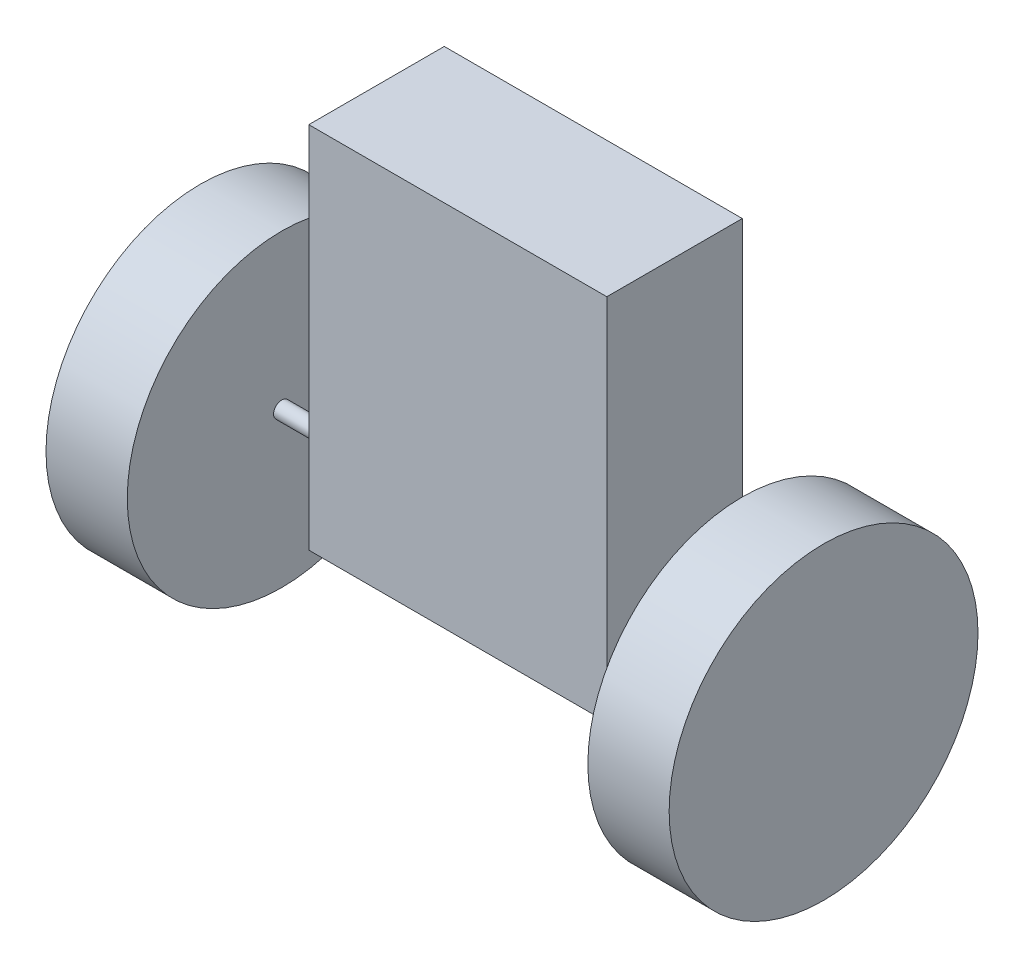
from build123d import *

# Parameters (mm, degrees)
ESQUISSE1_W        = 55
ESQUISSE1_H        = 68
BOSS_EXTRU_1_DEPTH = 25
ESQUISSE3_R        = 1.5
BOSS_EXTRU_2_DEPTH = 20
BOSS_EXTRU_3_START = -5
ESQUISSE4_R        = 28.5
BOSS_EXTRU_3_DEPTH = 15
ESQUISSE5_W        = 5
ESQUISSE5_H        = 5
BOSS_EXTRU_4_DEPTH = 2


with BuildPart() as part:
    # Esquisse1 → Boss.-Extru.1 (new body)
    with BuildSketch(Plane.XY):
        Rectangle(ESQUISSE1_W, ESQUISSE1_H)
    extrude(amount=BOSS_EXTRU_1_DEPTH)

    # Esquisse3 → Boss.-Extru.2 (add)
    with BuildSketch(Plane.ZY.offset(27.5)):
        with Locations((15, -24)):
            Circle(ESQUISSE3_R)
    boss_extru_2 = extrude(amount=BOSS_EXTRU_2_DEPTH)

    # Symétrie1: Boss.-Extru.2 across plane
    add(boss_extru_2.mirror(Plane(origin=(0, 0, 0), x_dir=(0, 0, 1), z_dir=(1, 0, 0))))

    # Esquisse4 → Boss.-Extru.3 (add)
    with BuildSketch(Plane.ZY.offset(47.5).offset(BOSS_EXTRU_3_START)):
        with Locations((15, -24)):
            Circle(ESQUISSE4_R)
    boss_extru_3 = extrude(amount=BOSS_EXTRU_3_DEPTH)

    # Symétrie2: Boss.-Extru.3 across plane
    add(boss_extru_3.mirror(Plane(origin=(0, 0, 0), x_dir=(0, 0, 1), z_dir=(1, 0, 0))))

    # Esquisse5 → Boss.-Extru.4 (add)
    with BuildSketch(Plane(origin=(0, 0, 0), x_dir=(-1, 0, 0), z_dir=(0, 0, -1))):
        with Locations((30, -25.993461036)):
            Rectangle(ESQUISSE5_W, ESQUISSE5_H)
    boss_extru_4 = extrude(amount=-BOSS_EXTRU_4_DEPTH)

    # Esquisse9 → Dégagement M31 (revolve, cut)
    with BuildSketch(Plane(origin=(-30, -25.993461036, 0), x_dir=(0, 1, 0), z_dir=(1, 0, 0))):
        Polygon((0, 0), (0, 4.021463052), (1.7, 3), (1.7, 0), align=None)
    d_gagement_m31 = revolve(axis=Axis((-30, -25.993461036, -6.35), (0, 0, 1)), mode=Mode.SUBTRACT)

    # Symétrie3: Boss.-Extru.4, Dégagement M31 across plane
    add(boss_extru_4.mirror(Plane(origin=(0, 0, 0), x_dir=(0, 0, 1), z_dir=(1, 0, 0))))
    add(d_gagement_m31.mirror(Plane(origin=(0, 0, 0), x_dir=(0, 0, 1), z_dir=(1, 0, 0))), mode=Mode.SUBTRACT)


solid = part.part
